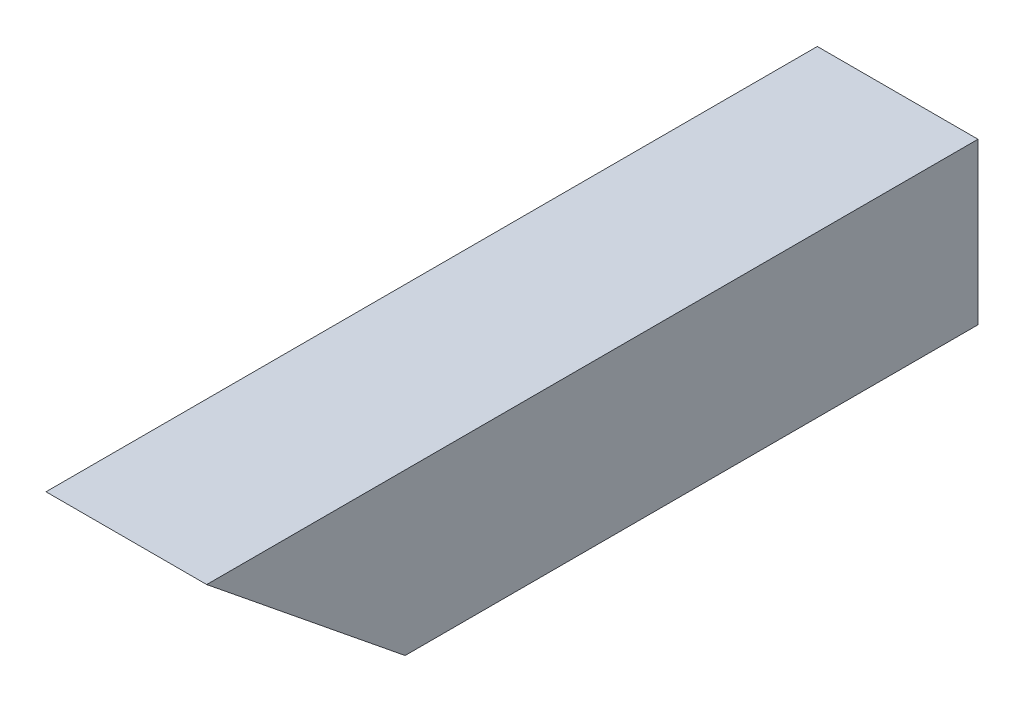
from build123d import *

# Parameters (mm, degrees)
SKETCH1_W               = 31.75
SKETCH1_H               = 31.75
SKETCH1_W_2             = 25.654
SKETCH1_H_2             = 25.654
BOSS_EXTRUDE1_DEPTH     = 152.4
CUT_EXTRUDE1_DEPTH      = 16.875
CUT_EXTRUDE1_DEPTH_BACK = 16.875


with BuildPart() as part:
    # Sketch1 → Boss-Extrude1 (new body)
    with BuildSketch(Plane.XY):
        Rectangle(SKETCH1_W, SKETCH1_H)
        Rectangle(SKETCH1_W_2, SKETCH1_H_2, mode=Mode.SUBTRACT)
    extrude(amount=BOSS_EXTRUDE1_DEPTH)

    # Sketch2 → Cut-Extrude1 (cut, two sides)
    with BuildSketch(Plane(origin=(0, 0, 0), x_dir=(0, 0, -1), z_dir=(1, 0, 0))) as cut_extrude1_sk:
        Polygon((-152.4, 15.875), (-113.19201528, -15.875), (-152.4, -15.875), align=None)
    extrude(amount=CUT_EXTRUDE1_DEPTH, mode=Mode.SUBTRACT)
    extrude(cut_extrude1_sk.sketch, amount=-CUT_EXTRUDE1_DEPTH_BACK, mode=Mode.SUBTRACT)


solid = part.part
